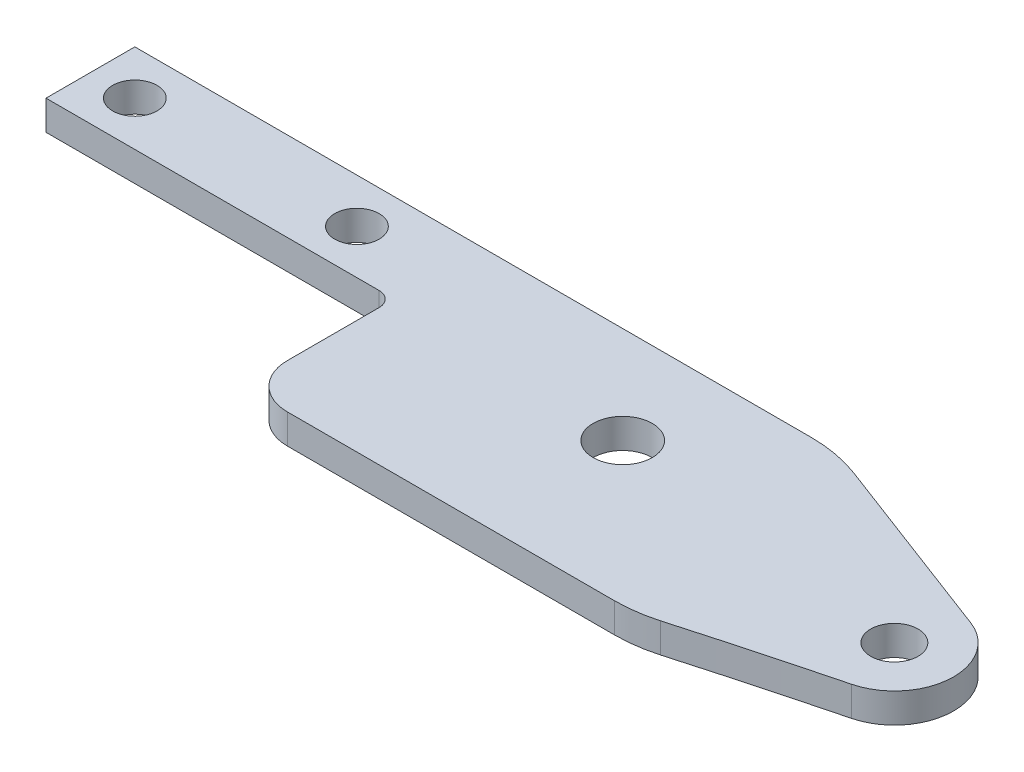
from build123d import *

# Parameters (mm, degrees)
SKETCH_2_R          = 1.5
SKETCH_2_R_2        = 1.6
EXTRUDE_2_DEPTH     = 2
FILLET_1_R          = 1
FILLET_2_R          = 10
SKETCH_3_R          = 2
CUT_EXTRUDE_1_DEPTH = 3


with BuildPart() as part:
    # 草图2 → 凸台-拉伸2 (new body)
    with BuildSketch(Plane(origin=(0, 0, 0), x_dir=(1, 0, 0), z_dir=(0, 1, 0))):
        with BuildLine():
            Line((44.5, 3), (-3, 3))
            Line((-3, 3), (-3, -3))
            Line((-3, -3), (20.5, -3))
            Line((20.5, -3), (20.5, -10.2))
            ThreePointArc((20.5, -10.2), (21.378679656, -12.321320344), (23.5, -13.2))
            Line((23.5, -13.2), (45.594157258, -13.2))
            ThreePointArc((45.594157258, -13.2), (46.977327515, -13.10388005), (48.333907722, -12.817368008))
            ThreePointArc((48.333907722, -12.817368008), (53.401969584, -11.411447703), (58.489004431, -10.075805753))
            ThreePointArc((58.489004431, -10.075805753), (61.493712967, -6.424180145), (58.916547929, -2.459225753))
            Line((58.916547929, -2.459225753), (44.5, 3))
        make_face()
        Circle(SKETCH_2_R, mode=Mode.SUBTRACT)
        with Locations((15, 0)):
            Circle(SKETCH_2_R, mode=Mode.SUBTRACT)
        with Locations((57.5, -6.2)):
            Circle(SKETCH_2_R_2, mode=Mode.SUBTRACT)
    extrude(amount=EXTRUDE_2_DEPTH)

    # 圆角1
    fillet_1_edges = [part.edges().sort_by_distance(p)[0] for p in [
        (20.5, 1, 3),
    ]]
    fillet(fillet_1_edges, radius=FILLET_1_R)

    # 圆角2
    fillet_2_edges = [part.edges().sort_by_distance(p)[0] for p in [
        (44.5, 1, -3),
    ]]
    fillet(fillet_2_edges, radius=FILLET_2_R)

    # 草图3 → 切除-拉伸1 (cut, through all)
    with BuildSketch(Plane(origin=(0, 2, 0), x_dir=(1, 0, 0), z_dir=(0, 1, 0))):
        with Locations((36.5, -3.55)):
            Circle(SKETCH_3_R)
    extrude(amount=-CUT_EXTRUDE_1_DEPTH, mode=Mode.SUBTRACT)


solid = part.part
